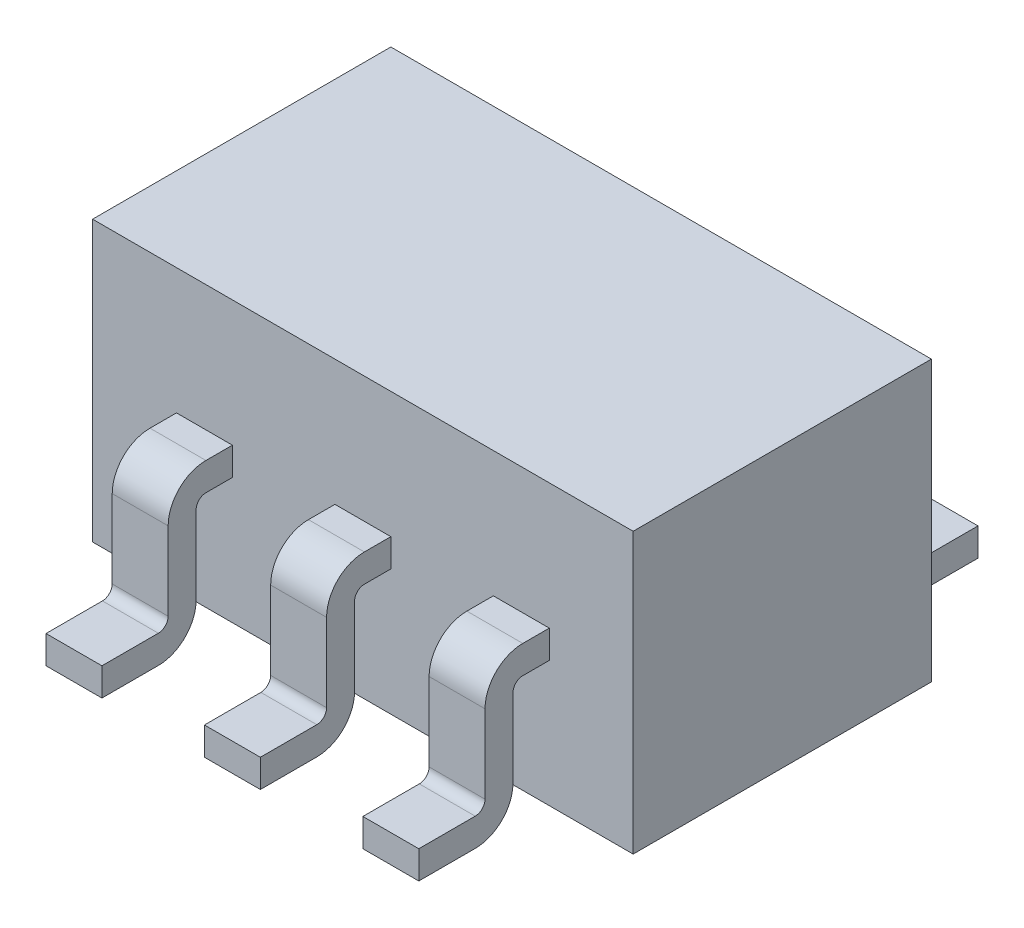
from build123d import *

# Parameters (mm, degrees)
SKETCH1_W           = 2.9
SKETCH1_H           = 1.6
BOSS_EXTRUDE1_DEPTH = 1.5
SKETCH2_W           = 0.3
SKETCH2_H           = 0.15
CIRPATTERN1_COUNT   = 2


with BuildPart() as part:
    # Sketch1 → Boss-Extrude1 (new body)
    with BuildSketch(Plane(origin=(0, 0, 0), x_dir=(1, 0, 0), z_dir=(0, 1, 0))):
        with Locations((1.45, 0.8)):
            Rectangle(SKETCH1_W, SKETCH1_H)
    extrude(amount=BOSS_EXTRUDE1_DEPTH)


with BuildPart() as body_2:
    # Sweep3: sweep along a path in Sketch3
    with BuildLine(Plane(origin=(0, 0, 0), x_dir=(0, 0, -1), z_dir=(1, 0, 0))) as sweep3_path:
        Line((0, 0.75), (-0.142063205, 0.75))
        ThreePointArc((-0.142063205, 0.75), (-0.232325408, 0.712612171), (-0.269713237, 0.622349968))
        Line((-0.269713237, 0.622349968), (-0.269713237, 0.202650032))
        ThreePointArc((-0.269713237, 0.202650032), (-0.307101066, 0.112387829), (-0.397363269, 0.075))
        Line((-0.397363269, 0.075), (-0.7, 0.075))
    # Sketch2 → Sweep3 (sweep)
    with BuildSketch(Plane.XY):
        with Locations((0.6, 0.75)):
            Rectangle(SKETCH2_W, SKETCH2_H)
        with Locations((1.45, 0.75)):
            Rectangle(SKETCH2_W, SKETCH2_H)
        with Locations((2.3, 0.75)):
            Rectangle(SKETCH2_W, SKETCH2_H)
    sweep3 = sweep(path=sweep3_path.line)


with BuildPart() as part_1:
    add(part.part)

    # CirPattern1: Sweep3 ×2 about axis
    cirpattern1_axis = Axis((1.45, -0.507167286, -0.8), (0, 1, 0))
    for i in range(1, CIRPATTERN1_COUNT):
        add(sweep3.rotate(cirpattern1_axis, i * 360 / CIRPATTERN1_COUNT))


solid = Compound([body_2.part, part_1.part])
